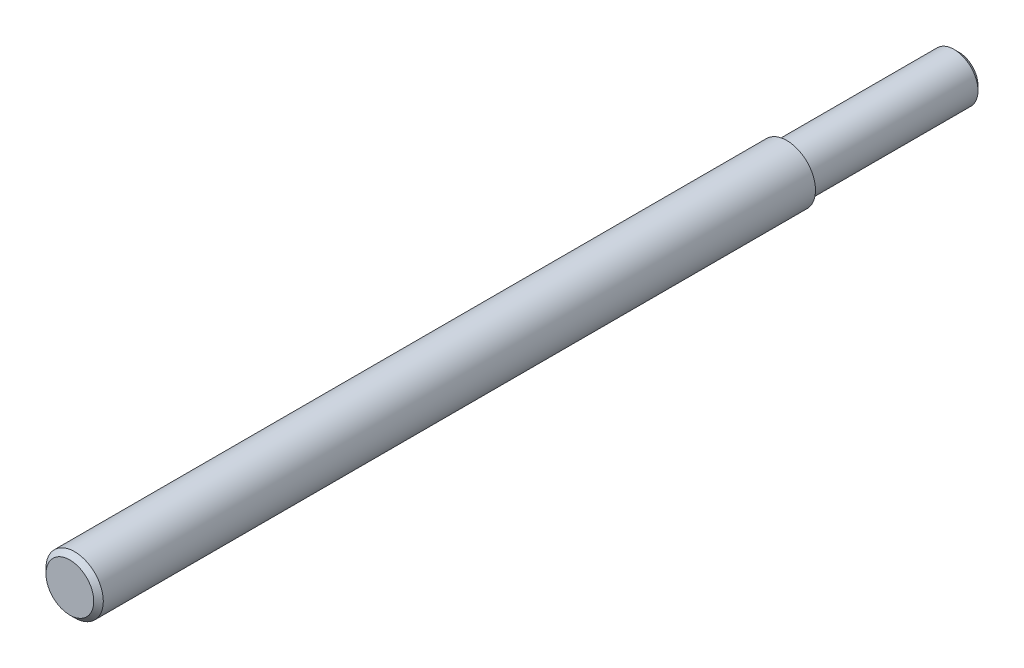
from build123d import *

# Parameters (mm, degrees)
SKETCH1_R           = 5
BOSS_EXTRUDE1_DEPTH = 36
SKETCH2_R           = 6
BOSS_EXTRUDE2_DEPTH = 150
CHAMFER1_SIZE       = 1


with BuildPart() as part:
    # Sketch1 → Boss-Extrude1 (new body)
    with BuildSketch(Plane.XY):
        Circle(SKETCH1_R)
    extrude(amount=BOSS_EXTRUDE1_DEPTH)

    # Sketch2 → Boss-Extrude2 (add)
    with BuildSketch(Plane.XY.offset(36)):
        Circle(SKETCH2_R)
    extrude(amount=BOSS_EXTRUDE2_DEPTH)

    # Chamfer1
    chamfer1_edges = [part.edges().sort_by_distance(p)[0] for p in [
        (-5, 0, 0),
        (-6, 0, 186),
    ]]
    chamfer(chamfer1_edges, length=CHAMFER1_SIZE)


solid = part.part
